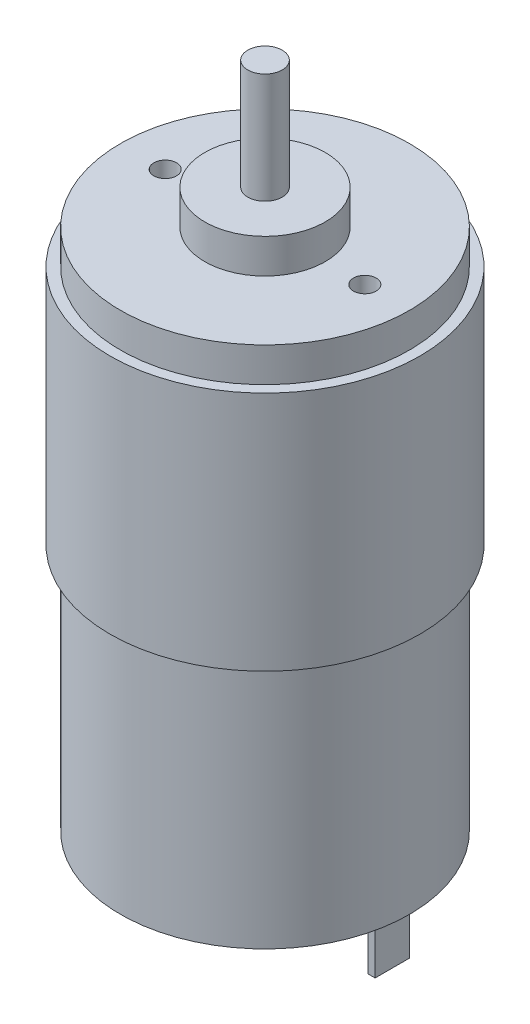
from build123d import *

# Parameters (mm, degrees)
SKETCH2_R           = 1.65
CUT_EXTRUDE1_DEPTH  = 20
SKETCH3_W           = 1
SKETCH3_H           = 5
BOSS_EXTRUDE1_DEPTH = 8


with BuildPart() as part:
    # Sketch1 → Revolve1 (revolve)
    with BuildSketch(Plane.XY):
        Polygon((0, 0), (0, 105), (2.5, 105), (2.5, 89), (8.75, 89), (8.75, 84), (21, 84), (21, 79), (22.5, 79), (22.5, 44), (21, 44), (21, 8), (8.75, 8), (8.75, 3), (2.5, 3), (2.5, 0), align=None)
    revolve(axis=Axis((0, 0, 0), (0, 1, 0)))

    # Sketch2 → Cut-Extrude1 (cut)
    with BuildSketch(Plane(origin=(0, 84, 0), x_dir=(1, 0, 0), z_dir=(0, 1, 0))):
        with Locations((14.5, 0)):
            Circle(SKETCH2_R)
        with Locations((-14.5, 0)):
            Circle(SKETCH2_R)
    extrude(amount=-CUT_EXTRUDE1_DEPTH, mode=Mode.SUBTRACT)

    # Sketch3 → Boss-Extrude1 (add)
    with BuildSketch(Plane.XZ.offset(-8)):
        with Locations((-18, 0)):
            Rectangle(SKETCH3_W, SKETCH3_H)
        with Locations((18, 0)):
            Rectangle(SKETCH3_W, SKETCH3_H)
    extrude(amount=BOSS_EXTRUDE1_DEPTH)


solid = part.part
